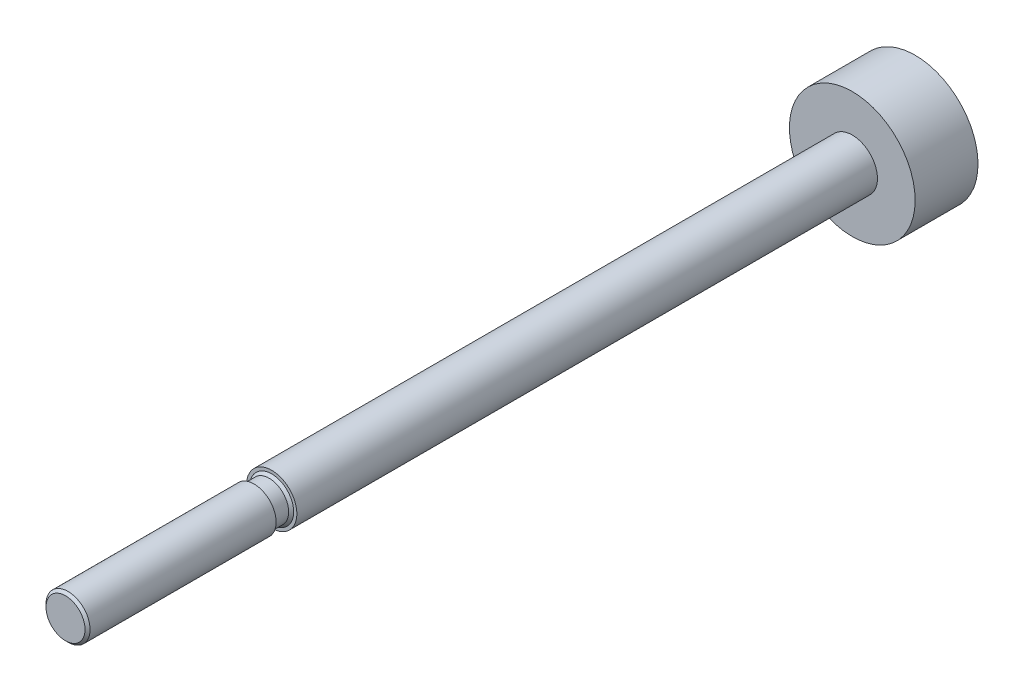
from build123d import *

# Parameters (mm, degrees)
SKETCH1_R          = 2
BASE_EXTRUDE_DEPTH = 65.085
SKETCH2_R          = 5
PISTON_DEPTH       = 2.5


with BuildPart() as part:
    # Sketch1 → Base-Extrude (new body)
    with BuildSketch(Plane.XY):
        Circle(SKETCH1_R)
    extrude(amount=BASE_EXTRUDE_DEPTH)

    # Sketch2 → Piston (add, symmetric)
    with BuildSketch(Plane.XY):
        Circle(SKETCH2_R)
    extrude(amount=PISTON_DEPTH, both=True)

    # Sketch3 → Threads (revolve, cut)
    with BuildSketch(Plane(origin=(0, 0, 0), x_dir=(0, 0, -1), z_dir=(1, 0, 0))):
        Polygon((-65.085, 1.5525), (-64.885, 1.7525), (-50.085, 1.7525), (-50.085, 1.55), (-48.885, 1.55), (-48.685, 1.75), (-48.685, 5), (-65.085, 5), align=None)
    revolve(axis=Axis((0, 0, 0), (0, 0, 1)), mode=Mode.SUBTRACT)


solid = part.part
